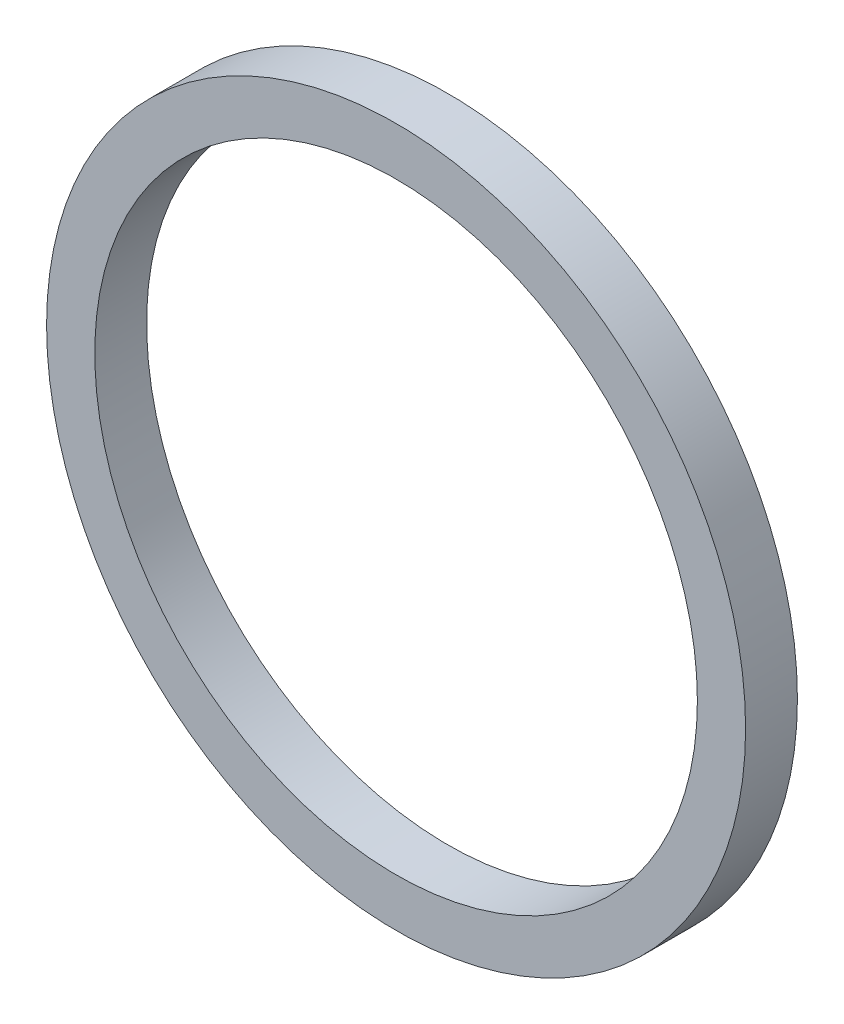
from build123d import *

# Parameters (mm, degrees)
SKETCH1_R           = 87
SKETCH1_R_2         = 75
BOSS_EXTRUDE1_DEPTH = 12.9


with BuildPart() as part:
    # Sketch1 → Boss-Extrude1 (new body)
    with BuildSketch(Plane.XY):
        Circle(SKETCH1_R)
        Circle(SKETCH1_R_2, mode=Mode.SUBTRACT)
    extrude(amount=BOSS_EXTRUDE1_DEPTH)


solid = part.part
